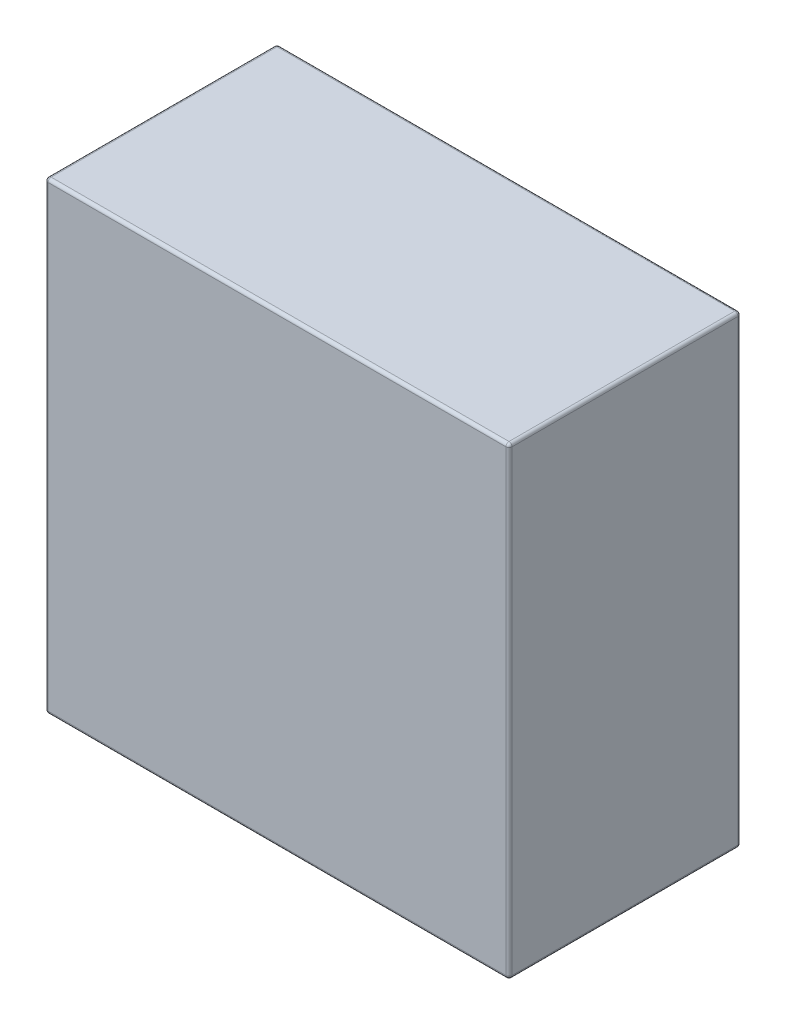
from build123d import *

# Parameters (mm, degrees)
SKETCH_1_W      = 300
SKETCH_1_H      = 300
EXTRUDE_1_DEPTH = 150
FILLET_1_R      = 2


with BuildPart() as part:
    # 草图1 → 凸台-拉伸1 (new body)
    with BuildSketch(Plane.XY):
        with Locations((150, 150)):
            Rectangle(SKETCH_1_W, SKETCH_1_H)
    extrude(amount=EXTRUDE_1_DEPTH)

    # 圆角1
    fillet_1_edges = [part.edges().sort_by_distance(p)[0] for p in [
        (300, 150, 150),
        (150, 300, 150),
        (0, 150, 150),
        (150, 300, 0),
        (300, 150, 0),
        (150, 0, 0),
        (0, 150, 0),
        (150, 0, 150),
        (0, 300, 75),
        (300, 300, 75),
        (300, 0, 75),
        (0, 0, 75),
    ]]
    fillet(fillet_1_edges, radius=FILLET_1_R)


solid = part.part
